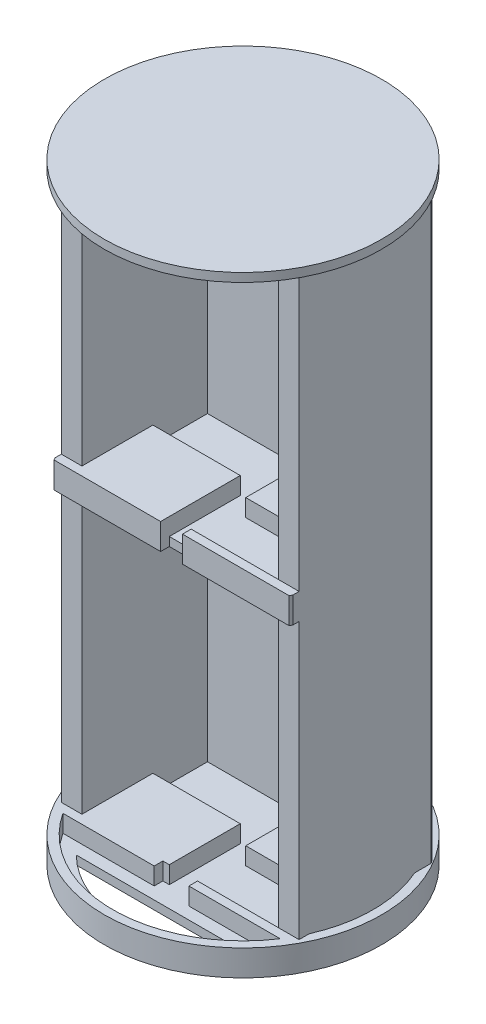
from build123d import *

# Parameters (mm, degrees)
SKETCH1_R            = 50.8
BOSS_EXTRUDE1_DEPTH  = 1
SKETCH4_W            = 6.35
SKETCH4_H            = 3
BOSS_EXTRUDE2_DEPTH  = 6.35
SKETCH6_R            = 50.8
SKETCH6_R_2          = 47.625
BOSS_EXTRUDE3_DEPTH  = 6.35
BOSS_EXTRUDE5_DEPTH  = 107.280000006
BOSS_EXTRUDE10_START = -6.35
BOSS_EXTRUDE10_DEPTH = 107.28
SKETCH12_W           = 72.000000018
SKETCH12_H           = 46
BOSS_EXTRUDE13_DEPTH = 3.175
BOSS_EXTRUDE14_DEPTH = 6.35
BOSS_EXTRUDE16_DEPTH = 6.35
BOSS_EXTRUDE17_DEPTH = 9.525
BOSS_EXTRUDE18_DEPTH = 101
SKETCH18_W           = 7.999999982
SKETCH18_H           = 6.35
BOSS_EXTRUDE19_DEPTH = 3.175
SKETCH19_W           = 7.999999982
SKETCH19_H           = 6
CUT_EXTRUDE1_DEPTH   = 6.35
SKETCH20_W           = 7.999999982
SKETCH20_H           = 6
CUT_EXTRUDE2_DEPTH   = 6.35
BOSS_EXTRUDE21_DEPTH = 6
CUT_EXTRUDE3_DEPTH   = 2
SKETCH24_R           = 50.8
BOSS_EXTRUDE22_DEPTH = 6.35
SKETCH25_R           = 50.8
CUT_EXTRUDE4_DEPTH   = 3.175
SKETCH26_R           = 50.8
BOSS_EXTRUDE23_DEPTH = 5.35
SKETCH28_R           = 60.968632161
CUT_EXTRUDE5_DEPTH   = 3.175


with BuildPart() as part:
    # Sketch1 → Boss-Extrude1 (new body)
    with BuildSketch(Plane(origin=(0, 0, 0), x_dir=(1, 0, 0), z_dir=(0, 1, 0))):
        Circle(SKETCH1_R)
    extrude(amount=BOSS_EXTRUDE1_DEPTH)

    # Sketch4 → Boss-Extrude2 (add)
    with BuildSketch(Plane(origin=(0, 1, 0), x_dir=(1, 0, 0), z_dir=(0, 1, 0))):
        Polygon((-36.000000009, 18), (-36.000000009, 23), (-26.000000009, 23), (-6.35, 23), (-6.35, 26.175), (-39.175000009, 26.175), (-39.175000009, -26.175), (-6.35, -26.175), (-6.35, -23), (-36.000000009, -23), (-36.000000009, 3), align=None)
        Polygon((6.35, 26.175), (6.35, 23), (36.000000009, 23), (36.000000009, -3), (36.000000009, -18), (36.000000009, -23), (26.000000009, -23), (6.35, -23), (6.35, -26.175), (39.175000009, -26.175), (39.175000009, 26.175), align=None)
        Polygon((-26.000000009, 3), (-36.000000009, 3), (-36.000000009, -23), (-6.35, -23), (-6.35, 0), (-6.35, 3), align=None)
        Polygon((36.000000009, 23), (6.35, 23), (6.35, 0), (6.35, -3), (26.000000009, -3), (36.000000009, -3), align=None)
        with Locations((-3.175, 1.5)):
            Rectangle(SKETCH4_W, SKETCH4_H)
        Polygon((6.35, 23), (3.999999991, 23), (3.999999991, 18), (3.999999991, 3), (0, 3), (0, 0), (6.35, 0), align=None)
        with Locations((3.175, -1.5)):
            Rectangle(SKETCH4_W, SKETCH4_H)
        Polygon((-6.35, 0), (-6.35, -23), (-3.999999991, -23), (-3.999999991, -18), (-3.999999991, -3), (0, -3), (0, 0), align=None)
    extrude(amount=BOSS_EXTRUDE2_DEPTH)

    # Sketch6 → Boss-Extrude3 (add)
    with BuildSketch(Plane(origin=(0, 1, 0), x_dir=(1, 0, 0), z_dir=(0, 1, 0))):
        Circle(SKETCH6_R)
        Circle(SKETCH6_R_2, mode=Mode.SUBTRACT)
    extrude(amount=BOSS_EXTRUDE3_DEPTH)

    # Sketch8 → Boss-Extrude5 (add)
    with BuildSketch(Plane(origin=(0, 1, 0), x_dir=(1, 0, 0), z_dir=(0, 1, 0))):
        with BuildLine():
            Line((-39.175000009, -23), (-39.175000009, 23))
            Line((-39.175000009, 23), (-41.703004988, 23))
            ThreePointArc((-41.703004988, 23), (-42.660279406, 21.171707206), (-43.537447961, 19.30365898))
            Line((-43.537447961, 19.30365898), (-43.537447961, -19.30365898))
            ThreePointArc((-43.537447961, -19.30365898), (-42.660279406, -21.171707206), (-41.703004988, -23))
            Line((-41.703004988, -23), (-39.175000009, -23))
        make_face()
        Polygon((-36.000000009, 3), (-36.000000009, 23), (-39.175000009, 23), (-39.175000009, -23), (-36.000000009, -23), align=None)
        Polygon((39.175000009, 23), (36.000000009, 23), (36.000000009, -3), (36.000000009, -23), (39.175000009, -23), align=None)
        with BuildLine():
            ThreePointArc((43.537447961, 19.30365898), (42.660279406, 21.171707206), (41.703004988, 23))
            Line((41.703004988, 23), (39.175000009, 23))
            Line((39.175000009, 23), (39.175000009, -23))
            Line((39.175000009, -23), (41.703004988, -23))
            ThreePointArc((41.703004988, -23), (42.660279406, -21.171707206), (43.537447961, -19.30365898))
            Line((43.537447961, -19.30365898), (43.537447961, 19.30365898))
        make_face()
        with BuildLine():
            Line((43.537447961, 23), (41.703004988, 23))
            ThreePointArc((41.703004988, 23), (42.660279406, 21.171707206), (43.537447961, 19.30365898))
            Line((43.537447961, 19.30365898), (43.537447961, 23))
        make_face()
        with BuildLine():
            ThreePointArc((43.537447961, -19.30365898), (42.660279406, -21.171707206), (41.703004988, -23))
            Line((41.703004988, -23), (43.537447961, -23))
            Line((43.537447961, -23), (43.537447961, -19.30365898))
        make_face()
        with BuildLine():
            Line((-43.537447961, -23), (-41.703004988, -23))
            ThreePointArc((-41.703004988, -23), (-42.660279406, -21.171707206), (-43.537447961, -19.30365898))
            Line((-43.537447961, -19.30365898), (-43.537447961, -23))
        make_face()
        with BuildLine():
            ThreePointArc((-43.537447961, 19.30365898), (-42.660279406, 21.171707206), (-41.703004988, 23))
            Line((-41.703004988, 23), (-43.537447961, 23))
            Line((-43.537447961, 23), (-43.537447961, 19.30365898))
        make_face()
    extrude(amount=BOSS_EXTRUDE5_DEPTH)

    # Sketch9 → Boss-Extrude10 (add)
    with BuildSketch(Plane(origin=(0, 7.35, 0), x_dir=(1, 0, 0), z_dir=(0, 1, 0)).offset(BOSS_EXTRUDE10_START)):
        with BuildLine():
            Line((-43.537447961, 25.31123991), (-43.537447961, 23))
            Line((-43.537447961, 23), (43.537447961, 23))
            Line((43.537447961, 23), (43.537447961, 25.31123991))
            ThreePointArc((43.537447961, 25.31123991), (43.28272205, 25.744401579), (43.023686683, 26.175))
            Line((43.023686683, 26.175), (-43.023686683, 26.175))
            ThreePointArc((-43.023686683, 26.175), (-43.28272205, 25.744401579), (-43.537447961, 25.31123991))
        make_face()
    extrude(amount=BOSS_EXTRUDE10_DEPTH)

    # Sketch12 → Boss-Extrude13 (add)
    with BuildSketch(Plane(origin=(0, 108.280000006, 0), x_dir=(1, 0, 0), z_dir=(0, 1, 0))):
        with BuildLine():
            Line((-36.000000009, 23), (36.000000009, 23))
            Line((36.000000009, 23), (36.000000009, -23))
            Line((36.000000009, -23), (43.537447961, -23))
            Line((43.537447961, -23), (43.537447961, 25.31123991))
            ThreePointArc((43.537447961, 25.31123991), (43.28272205, 25.744401579), (43.023686683, 26.175))
            Line((43.023686683, 26.175), (-43.023686683, 26.175))
            ThreePointArc((-43.023686683, 26.175), (-43.28272205, 25.744401579), (-43.537447961, 25.31123991))
            Line((-43.537447961, 25.31123991), (-43.537447961, -23))
            Line((-43.537447961, -23), (-36.000000009, -23))
            Line((-36.000000009, -23), (-36.000000009, 23))
        make_face()
        Rectangle(SKETCH12_W, SKETCH12_H)
    extrude(amount=BOSS_EXTRUDE13_DEPTH)

    # Sketch13 → Boss-Extrude14 (add)
    with BuildSketch(Plane(origin=(0, 111.455000006, 0), x_dir=(1, 0, 0), z_dir=(0, 1, 0))):
        Polygon((-3.999999991, -3), (36.000000009, -3), (36.000000009, 23), (3.999999991, 23), (3.999999991, 3), (-36.000000009, 3), (-36.000000009, -23), (-6.35, -23), (-3.999999991, -23), align=None)
        with BuildLine():
            Line((36.000000009, -23), (39.175000009, -23))
            Line((39.175000009, -23), (41.703004988, -23))
            Line((41.703004988, -23), (43.537447961, -23))
            Line((43.537447961, -23), (43.537447961, 25.31123991))
            ThreePointArc((43.537447961, 25.31123991), (43.28272205, 25.744401579), (43.023686683, 26.175))
            Line((43.023686683, 26.175), (3.999999991, 26.175))
            Line((3.999999991, 26.175), (3.999999991, 23))
            Line((3.999999991, 23), (36.000000009, 23))
            Line((36.000000009, 23), (36.000000009, -3))
            Line((36.000000009, -3), (36.000000009, -23))
        make_face()
        with BuildLine():
            Line((-43.537447961, -23), (-41.703004988, -23))
            Line((-41.703004988, -23), (-39.175000009, -23))
            Line((-39.175000009, -23), (-36.000000009, -23))
            Line((-36.000000009, -23), (-36.000000009, 3))
            Line((-36.000000009, 3), (-36.000000009, 23))
            Line((-36.000000009, 23), (-3.999999991, 23))
            Line((-3.999999991, 23), (-3.999999991, 26.175))
            Line((-3.999999991, 26.175), (-43.023686683, 26.175))
            ThreePointArc((-43.023686683, 26.175), (-43.28272205, 25.744401579), (-43.537447961, 25.31123991))
            Line((-43.537447961, 25.31123991), (-43.537447961, -23))
        make_face()
    extrude(amount=BOSS_EXTRUDE14_DEPTH)

    # Sketch15 → Boss-Extrude16 (add)
    with BuildSketch(Plane(origin=(0, 1, 0), x_dir=(1, 0, 0), z_dir=(0, 1, 0))):
        with BuildLine():
            Line((39.175000009, -26.175), (39.787058197, -26.175))
            ThreePointArc((39.787058197, -26.175), (40.775945798, -24.60615511), (41.703004988, -23))
            Line((41.703004988, -23), (39.175000009, -23))
            Line((39.175000009, -23), (39.175000009, -26.175))
        make_face()
        with BuildLine():
            Line((-39.787058197, -26.175), (-39.175000009, -26.175))
            Line((-39.175000009, -26.175), (-39.175000009, -23))
            Line((-39.175000009, -23), (-41.703004988, -23))
            ThreePointArc((-41.703004988, -23), (-40.775945798, -24.60615511), (-39.787058197, -26.175))
        make_face()
    extrude(amount=BOSS_EXTRUDE16_DEPTH)

    # Sketch16 → Boss-Extrude17 (add)
    with BuildSketch(Plane(origin=(0, 117.805000006, 0), x_dir=(1, 0, 0), z_dir=(0, 1, 0))):
        with BuildLine():
            Line((-3.999999991, -23), (-43.537447961, -23))
            Line((-43.537447961, -23), (-43.537447961, -25.31123991))
            ThreePointArc((-43.537447961, -25.31123991), (-43.28272205, -25.744401579), (-43.023686683, -26.175))
            Line((-43.023686683, -26.175), (-3.999999991, -26.175))
            Line((-3.999999991, -26.175), (-3.999999991, -23))
        make_face()
        with BuildLine():
            Line((43.537447961, -23), (3.999999991, -23))
            Line((3.999999991, -23), (3.999999991, -26.175))
            Line((3.999999991, -26.175), (43.023686683, -26.175))
            ThreePointArc((43.023686683, -26.175), (43.28272205, -25.744401579), (43.537447961, -25.31123991))
            Line((43.537447961, -25.31123991), (43.537447961, -23))
        make_face()
    extrude(amount=-BOSS_EXTRUDE17_DEPTH)

    # Sketch17 → Boss-Extrude18 (add)
    with BuildSketch(Plane(origin=(0, 117.805000006, 0), x_dir=(1, 0, 0), z_dir=(0, 1, 0))):
        with BuildLine():
            ThreePointArc((43.537447961, 25.31123991), (43.28272205, 25.744401579), (43.023686683, 26.175))
            Line((43.023686683, 26.175), (-43.023686683, 26.175))
            ThreePointArc((-43.023686683, 26.175), (-43.28272205, 25.744401579), (-43.537447961, 25.31123991))
            Line((-43.537447961, 25.31123991), (-43.537447961, -23))
            Line((-43.537447961, -23), (-36.000000009, -23))
            Line((-36.000000009, -23), (-36.000000009, 23))
            Line((-36.000000009, 23), (36.000000009, 23))
            Line((36.000000009, 23), (36.000000009, -23))
            Line((36.000000009, -23), (43.537447961, -23))
            Line((43.537447961, -23), (43.537447961, 25.31123991))
        make_face()
    extrude(amount=BOSS_EXTRUDE18_DEPTH)

    # Sketch18 → Boss-Extrude19 (add)
    with BuildSketch(Plane(origin=(0, 0, -26.175), x_dir=(-1, 0, 0), z_dir=(0, 0, -1))):
        with Locations((0, 114.630000006)):
            Rectangle(SKETCH18_W, SKETCH18_H)
    extrude(amount=-BOSS_EXTRUDE19_DEPTH)

    # Sketch19 → Cut-Extrude1 (cut)
    with BuildSketch(Plane(origin=(0, 117.805000006, 0), x_dir=(1, 0, 0), z_dir=(0, 1, 0))):
        Rectangle(SKETCH19_W, SKETCH19_H)
    extrude(amount=-CUT_EXTRUDE1_DEPTH, mode=Mode.SUBTRACT)

    # Sketch20 → Cut-Extrude2 (cut)
    with BuildSketch(Plane(origin=(0, 7.35, 0), x_dir=(1, 0, 0), z_dir=(0, 1, 0))):
        Rectangle(SKETCH20_W, SKETCH20_H)
    extrude(amount=-CUT_EXTRUDE2_DEPTH, mode=Mode.SUBTRACT)

    # Sketch21 → Boss-Extrude21 (add)
    with BuildSketch(Plane(origin=(0, 218.805000006, 0), x_dir=(1, 0, 0), z_dir=(0, 1, 0))):
        with BuildLine():
            Line((-43.537447961, 25.31123991), (-43.537447961, -23))
            Line((-43.537447961, -23), (-36.000000009, -23))
            Line((-36.000000009, -23), (-36.000000009, 23))
            Line((-36.000000009, 23), (36.000000009, 23))
            Line((36.000000009, 23), (36.000000009, -23))
            Line((36.000000009, -23), (43.537447961, -23))
            Line((43.537447961, -23), (43.537447961, 25.31123991))
            ThreePointArc((43.537447961, 25.31123991), (43.28272205, 25.744401579), (43.023686683, 26.175))
            Line((43.023686683, 26.175), (-43.023686683, 26.175))
            ThreePointArc((-43.023686683, 26.175), (-43.28272205, 25.744401579), (-43.537447961, 25.31123991))
        make_face()
        with BuildLine():
            ThreePointArc((-43.537447961, -25.31123991), (-43.28272205, -25.744401579), (-43.023686683, -26.175))
            Line((-43.023686683, -26.175), (43.023686683, -26.175))
            ThreePointArc((43.023686683, -26.175), (43.28272205, -25.744401579), (43.537447961, -25.31123991))
            Line((43.537447961, -25.31123991), (43.537447961, -23))
            Line((43.537447961, -23), (36.000000009, -23))
            Line((36.000000009, -23), (36.000000009, 23))
            Line((36.000000009, 23), (-36.000000009, 23))
            Line((-36.000000009, 23), (-36.000000009, -23))
            Line((-36.000000009, -23), (-43.537447961, -23))
            Line((-43.537447961, -23), (-43.537447961, -25.31123991))
        make_face()
    extrude(amount=BOSS_EXTRUDE21_DEPTH)

    # Sketch23 → Cut-Extrude3 (cut, through all)
    with BuildSketch(Plane(origin=(0, 1, 0), x_dir=(1, 0, 0), z_dir=(0, 1, 0))):
        with BuildLine():
            Line((-6.35, -30.62), (-30.445492277, -30.62))
            ThreePointArc((-30.445492277, -30.62), (0, -43.18), (30.445492277, -30.62))
            Line((30.445492277, -30.62), (6.35, -30.62))
            Line((6.35, -30.62), (-6.35, -30.62))
        make_face()
        with BuildLine():
            Line((-30.445492277, 30.62), (30.445492277, 30.62))
            ThreePointArc((30.445492277, 30.62), (0, 43.18), (-30.445492277, 30.62))
        make_face()
    extrude(amount=-CUT_EXTRUDE3_DEPTH, mode=Mode.SUBTRACT)

    # Sketch24 → Boss-Extrude22 (add)
    with BuildSketch(Plane(origin=(0, 224.805000006, 0), x_dir=(1, 0, 0), z_dir=(0, 1, 0))):
        Circle(SKETCH24_R)
    extrude(amount=-BOSS_EXTRUDE22_DEPTH)

    # Sketch25 → Cut-Extrude4 (cut)
    with BuildSketch(Plane(origin=(0, 224.805000006, 0), x_dir=(1, 0, 0), z_dir=(0, 1, 0))):
        Circle(SKETCH25_R)
    extrude(amount=-CUT_EXTRUDE4_DEPTH, mode=Mode.SUBTRACT)

    # Sketch26 → Boss-Extrude23 (add)
    with BuildSketch(Plane.XZ):
        Circle(SKETCH26_R)
        with BuildLine():
            Line((-30.445492277, -30.62), (30.445492277, -30.62))
            ThreePointArc((30.445492277, -30.62), (0, -43.18), (-30.445492277, -30.62))
        make_face(mode=Mode.SUBTRACT)
        with BuildLine():
            Line((30.445492277, 30.62), (-30.445492277, 30.62))
            ThreePointArc((-30.445492277, 30.62), (0, 43.18), (30.445492277, 30.62))
        make_face(mode=Mode.SUBTRACT)
    extrude(amount=BOSS_EXTRUDE23_DEPTH)

    # Sketch28 → Cut-Extrude5 (cut)
    with BuildSketch(Plane.XZ.offset(5.35)):
        Circle(SKETCH28_R)
    extrude(amount=-CUT_EXTRUDE5_DEPTH, mode=Mode.SUBTRACT)


solid = part.part
